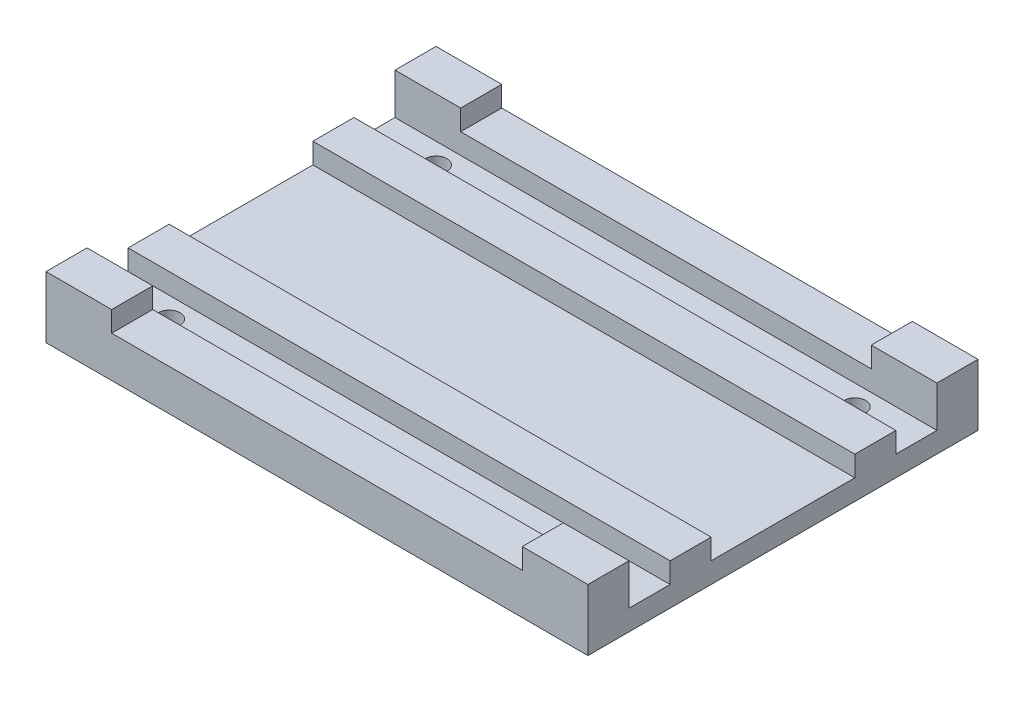
from build123d import *

# Parameters (mm, degrees)
SKETCH1_W            = 132
SKETCH1_H            = 95
BOSS_EXTRUDE1_DEPTH  = 5
M5_CLEARANCE_SLOT1_D = 5.3
SKETCH4_W            = 132
SKETCH4_H            = 10
BOSS_EXTRUDE2_DEPTH  = 10
SKETCH5_W            = 100
SKETCH5_H            = 10
SKETCH5_H_2          = 2.5
SKETCH5_W_2          = 16
CUT_EXTRUDE1_DEPTH   = 5


with BuildPart() as part:
    # Sketch1 → Boss-Extrude1 (new body)
    with BuildSketch(Plane(origin=(0, 0, 0), x_dir=(1, 0, 0), z_dir=(0, 1, 0))):
        Rectangle(SKETCH1_W, SKETCH1_H)
    extrude(amount=BOSS_EXTRUDE1_DEPTH)

    # M5 Clearance Slot1 (through all)
    with Locations(Plane(origin=(0, 5, 0), x_dir=(1, 0, 0), z_dir=(0, 1, 0))):
        with Locations((-51, 32.5), (51, 32.5), (51, -32.5), (-51, -32.5)):
            Hole(M5_CLEARANCE_SLOT1_D / 2)

    # Sketch4 → Boss-Extrude2 (add)
    with BuildSketch(Plane(origin=(0, 5, 0), x_dir=(1, 0, 0), z_dir=(0, 1, 0))):
        with Locations((0, 22.5)):
            Rectangle(SKETCH4_W, SKETCH4_H)
        with Locations((0, 42.5)):
            Rectangle(SKETCH4_W, SKETCH4_H)
        with Locations((0, -22.5)):
            Rectangle(SKETCH4_W, SKETCH4_H)
        with Locations((0, -42.5)):
            Rectangle(SKETCH4_W, SKETCH4_H)
    extrude(amount=BOSS_EXTRUDE2_DEPTH)

    # Sketch5 → Cut-Extrude1 (cut)
    with BuildSketch(Plane(origin=(0, 15, 0), x_dir=(1, 0, 0), z_dir=(0, 1, 0))):
        Polygon((-50, -27.5), (-50, -37.5), (50, -37.5), (50, -27.5), (50, -17.5), (50, 17.5), (50, 27.5), (50, 50), (-50, 50), (-50, 27.5), (-50, 17.5), (-50, -17.5), align=None)
        with Locations((0, -42.5)):
            Rectangle(SKETCH5_W, SKETCH5_H)
        with Locations((0, -48.75)):
            Rectangle(SKETCH5_W, SKETCH5_H_2)
        with Locations((-58, -22.5)):
            Rectangle(SKETCH5_W_2, SKETCH5_H)
        with Locations((58, -22.5)):
            Rectangle(SKETCH5_W_2, SKETCH5_H)
        with Locations((58, 22.5)):
            Rectangle(SKETCH5_W_2, SKETCH5_H)
        with Locations((-58, 22.5)):
            Rectangle(SKETCH5_W_2, SKETCH5_H)
    extrude(amount=-CUT_EXTRUDE1_DEPTH, mode=Mode.SUBTRACT)


solid = part.part
